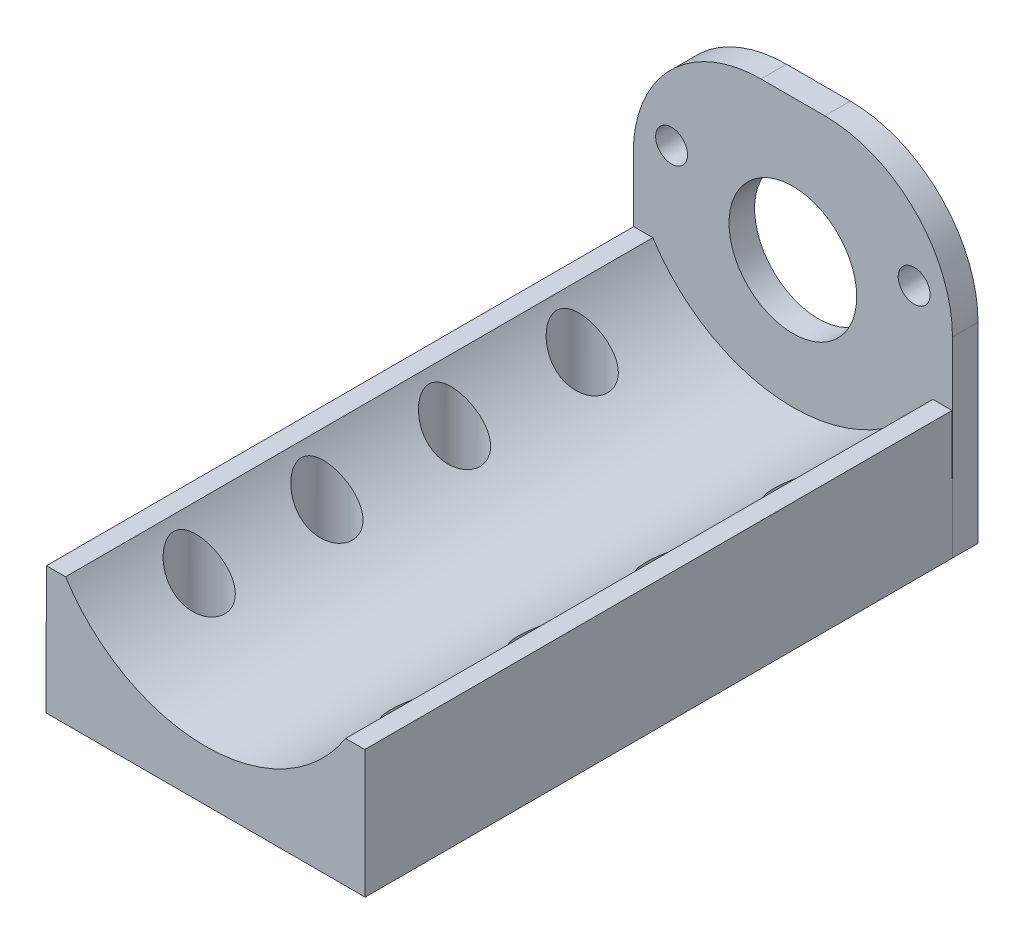
from build123d import *

# Parameters (mm, degrees)
BOSS_EXTRUDE1_DEPTH       = 46
SKETCH3_W                 = 25
SKETCH3_H                 = 25
BOSS_EXTRUDE2_DEPTH       = 2
SKETCH4_R                 = 1.25
SKETCH4_R_2               = 5
CUT_EXTRUDE1_DEPTH        = 3
FILLET1_R                 = 10
SKETCH5_R                 = 2
CUT_EXTRUDE2_DEPTH        = 26
LPATTERN1_COUNT           = 4
LPATTERN1_PITCH           = 10
LPATTERN1_COPY_1_SKETCH_R = 2
LPATTERN1_COPY_1_DEPTH    = 26
LPATTERN1_COPY_2_SKETCH_R = 2
LPATTERN1_COPY_2_DEPTH    = 26
LPATTERN1_COPY_3_SKETCH_R = 2
LPATTERN1_COPY_3_DEPTH    = 26


with BuildPart() as part:
    # Sketch2 → Boss-Extrude1 (new body)
    with BuildSketch(Plane.XY):
        with BuildLine():
            Line((-12.5, -3.978039328), (12.5, -3.978039328))
            Line((12.5, -3.978039328), (12.468421549, 6.021910812))
            Line((12.468421549, 6.021910812), (10.968421549, 6.021910812))
            ThreePointArc((10.968421549, 6.021910812), (0, 0), (-10.968421549, 6.021910812))
            Line((-10.968421549, 6.021910812), (-12.468421549, 6.021910812))
            Line((-12.468421549, 6.021910812), (-12.5, -3.978039328))
        make_face()
    extrude(amount=BOSS_EXTRUDE1_DEPTH)

    # Sketch3 → Boss-Extrude2 (add)
    with BuildSketch(Plane(origin=(0, 0, 0), x_dir=(-1, 0, 0), z_dir=(0, 0, -1))):
        with Locations((0, 8.521960672)):
            Rectangle(SKETCH3_W, SKETCH3_H)
    extrude(amount=BOSS_EXTRUDE2_DEPTH)

    # Sketch4 → Cut-Extrude1 (cut, through all)
    with BuildSketch(Plane.XY):
        with Locations((-9.5, 13)):
            Circle(SKETCH4_R)
        with Locations((9.5, 13)):
            Circle(SKETCH4_R)
        with Locations((0, 10)):
            Circle(SKETCH4_R_2)
    extrude(amount=-CUT_EXTRUDE1_DEPTH, mode=Mode.SUBTRACT)

    # Fillet1
    fillet1_edges = [part.edges().sort_by_distance(p)[0] for p in [
        (12.5, 21.021960672, -1),
        (-12.5, 21.021960672, -1),
    ]]
    fillet(fillet1_edges, radius=FILLET1_R)

    # Sketch5 → Cut-Extrude2 (cut, through all)
    with BuildSketch(Plane.XZ.offset(3.978039328)):
        with Locations((-8.5, 8)):
            Circle(SKETCH5_R)
    cut_extrude2 = extrude(amount=-CUT_EXTRUDE2_DEPTH, mode=Mode.SUBTRACT)

    # Mirror1: Cut-Extrude2 across plane
    add(cut_extrude2.mirror(Plane(origin=(0, 0, 0), x_dir=(0, 0, 1), z_dir=(1, 0, 0))), mode=Mode.SUBTRACT)

    # LPattern1: Cut-Extrude2 ×4
    with Locations(*[(0, 0, i * LPATTERN1_PITCH) for i in range(1, LPATTERN1_COUNT)]):
        add(cut_extrude2, mode=Mode.SUBTRACT)

    # LPattern1 copy 1 sketch → LPattern1 copy 1 (cut, through all)
    with BuildSketch(Plane(origin=(0, -3.978039328, 10), x_dir=(-1, 0, 0), z_dir=(0, -1, 0))):
        with Locations((-8.5, -8)):
            Circle(LPATTERN1_COPY_1_SKETCH_R)
    extrude(amount=-LPATTERN1_COPY_1_DEPTH, mode=Mode.SUBTRACT)

    # LPattern1 copy 2 sketch → LPattern1 copy 2 (cut, through all)
    with BuildSketch(Plane(origin=(0, -3.978039328, 20), x_dir=(-1, 0, 0), z_dir=(0, -1, 0))):
        with Locations((-8.5, -8)):
            Circle(LPATTERN1_COPY_2_SKETCH_R)
    extrude(amount=-LPATTERN1_COPY_2_DEPTH, mode=Mode.SUBTRACT)

    # LPattern1 copy 3 sketch → LPattern1 copy 3 (cut, through all)
    with BuildSketch(Plane(origin=(0, -3.978039328, 30), x_dir=(-1, 0, 0), z_dir=(0, -1, 0))):
        with Locations((-8.5, -8)):
            Circle(LPATTERN1_COPY_3_SKETCH_R)
    extrude(amount=-LPATTERN1_COPY_3_DEPTH, mode=Mode.SUBTRACT)


solid = part.part
